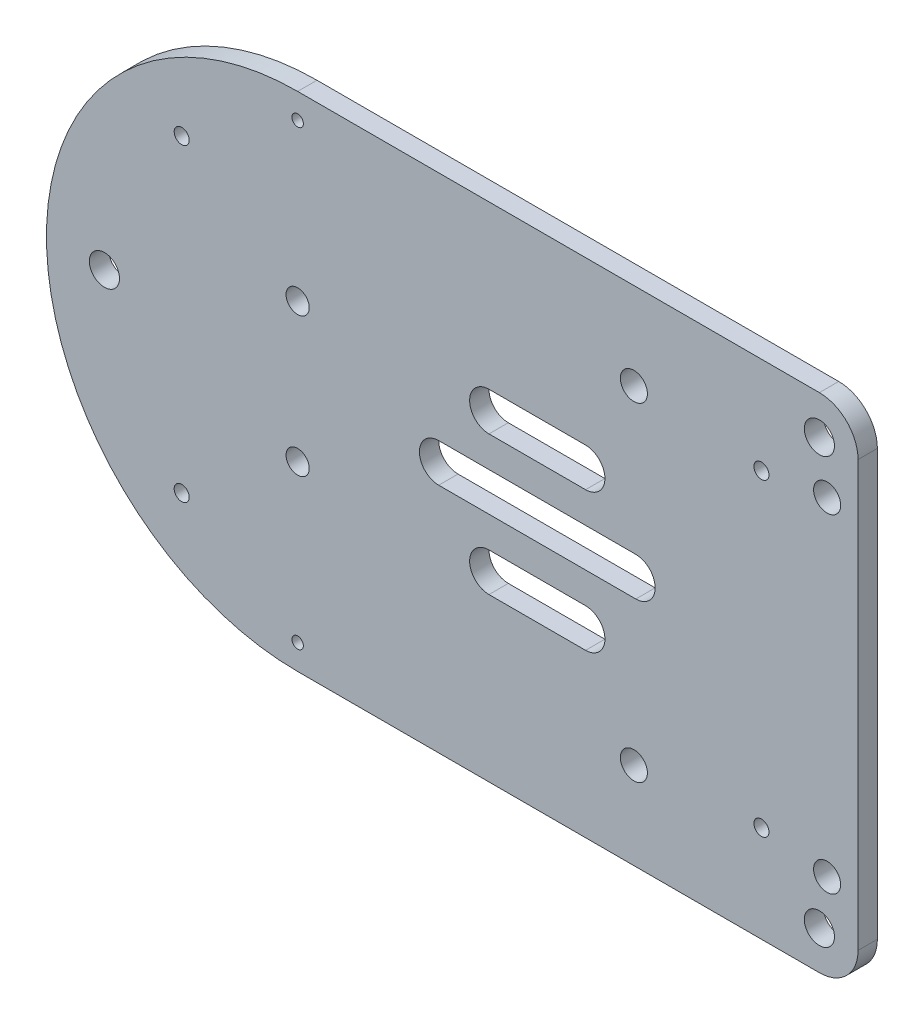
from build123d import *

# Parameters (mm, degrees)
SKETCH1_R           = 3.9
SKETCH1_R_2         = 3
SKETCH1_R_3         = 1.95
SKETCH1_R_4         = 3.5
SKETCH1_R_5         = 1.475
BOSS_EXTRUDE2_DEPTH = 5


with BuildPart() as part:
    # Sketch1 → Boss-Extrude2 (new body)
    with BuildSketch(Plane.XY):
        with BuildLine():
            Line((-40, -65), (95, -65))
            ThreePointArc((95, -65), (102.071067812, -62.071067812), (105, -55))
            Line((105, -55), (105, 55))
            ThreePointArc((105, 55), (102.071067812, 62.071067812), (95, 65))
            Line((95, 65), (-40, 65))
            ThreePointArc((-40, 65), (-105, 0), (-40, -65))
        make_face()
        with Locations((95, 55)):
            Circle(SKETCH1_R, mode=Mode.SUBTRACT)
        with Locations((95, -55)):
            Circle(SKETCH1_R, mode=Mode.SUBTRACT)
        with Locations((-90, 0)):
            Circle(SKETCH1_R, mode=Mode.SUBTRACT)
        with Locations((-40, -18)):
            Circle(SKETCH1_R_2, mode=Mode.SUBTRACT)
        with Locations((-40, 18)):
            Circle(SKETCH1_R_2, mode=Mode.SUBTRACT)
        with Locations((80, 40)):
            Circle(SKETCH1_R_3, mode=Mode.SUBTRACT)
        with Locations((80, -40)):
            Circle(SKETCH1_R_3, mode=Mode.SUBTRACT)
        with Locations((-70, 40)):
            Circle(SKETCH1_R_3, mode=Mode.SUBTRACT)
        with Locations((-70, -40)):
            Circle(SKETCH1_R_3, mode=Mode.SUBTRACT)
        with Locations((47, 42.5)):
            Circle(SKETCH1_R_4, mode=Mode.SUBTRACT)
        with Locations((97, 42.5)):
            Circle(SKETCH1_R_4, mode=Mode.SUBTRACT)
        with Locations((97, -42.5)):
            Circle(SKETCH1_R_4, mode=Mode.SUBTRACT)
        with Locations((47, -42.5)):
            Circle(SKETCH1_R_4, mode=Mode.SUBTRACT)
        with Locations((-40, 58.5)):
            Circle(SKETCH1_R_5, mode=Mode.SUBTRACT)
        with Locations((-40, -58.5)):
            Circle(SKETCH1_R_5, mode=Mode.SUBTRACT)
        with BuildLine():
            Line((-3.5, 5), (47.5, 5))
            ThreePointArc((47.5, 5), (52.5, 0), (47.5, -5))
            Line((47.5, -5), (-3.5, -5))
            ThreePointArc((-3.5, -5), (-8.5, 0), (-3.5, 5))
        make_face(mode=Mode.SUBTRACT)
        with BuildLine():
            Line((9.5, 23), (34.5, 23))
            ThreePointArc((34.5, 23), (39.5, 18), (34.5, 13))
            Line((34.5, 13), (9.5, 13))
            ThreePointArc((9.5, 13), (4.5, 18), (9.5, 23))
        make_face(mode=Mode.SUBTRACT)
        with BuildLine():
            Line((9.5, -23), (34.5, -23))
            ThreePointArc((34.5, -23), (39.5, -18), (34.5, -13))
            Line((34.5, -13), (9.5, -13))
            ThreePointArc((9.5, -13), (4.5, -18), (9.5, -23))
        make_face(mode=Mode.SUBTRACT)
    extrude(amount=BOSS_EXTRUDE2_DEPTH)


solid = part.part
